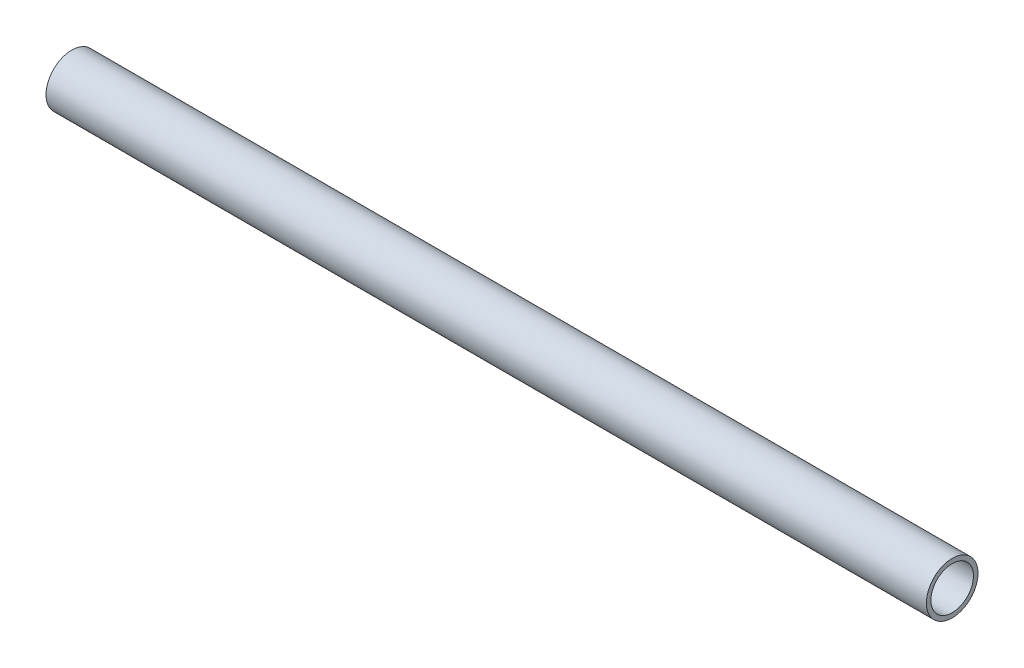
from build123d import *

# Parameters (mm, degrees)
SKETCH1_R               = 3.175
SKETCH1_R_2             = 2.6162
PIPE_0_5_SCH_40_1_DEPTH = 108.258498252


with BuildPart() as part:
    # Sketch1 → Pipe 0.5 SCH 40(1) (new body)
    with BuildSketch(Plane(origin=(-148.488053197, 657.250420928, 0), x_dir=(0, -1, 0), z_dir=(-1, 0, 0))):
        Circle(SKETCH1_R)
        Circle(SKETCH1_R_2, mode=Mode.SUBTRACT)
    extrude(amount=PIPE_0_5_SCH_40_1_DEPTH)


solid = part.part
